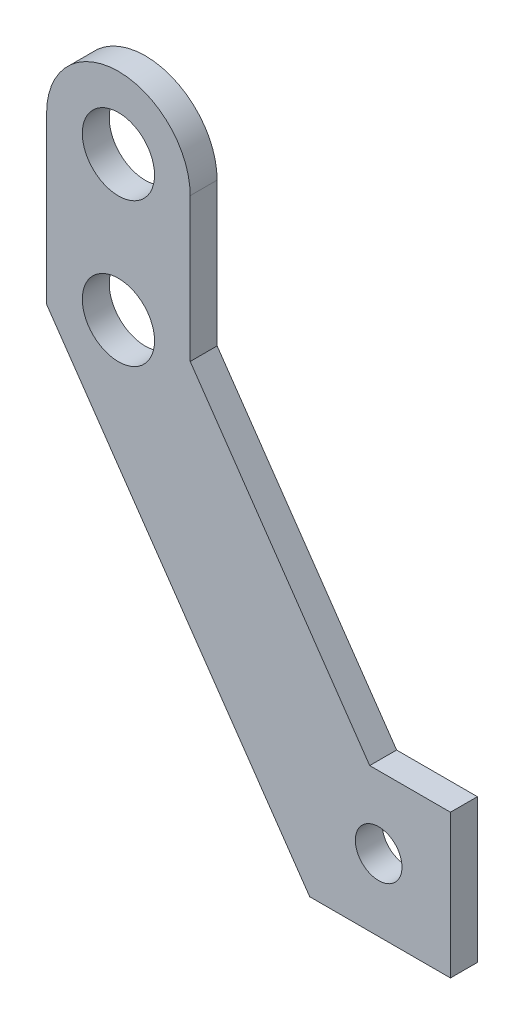
from build123d import *

# Parameters (mm, degrees)
SKETCH_1_R      = 2.6
SKETCH_1_R_2    = 4.025
EXTRUDE_1_DEPTH = 3


with BuildPart() as part:
    # ｽｹｯﾁ1 → ﾎﾞｽ - 押し出し1 (new body)
    with BuildSketch(Plane.XY):
        with BuildLine():
            Line((0, 46), (0, 27.508868037))
            Line((0, 27.508868037), (29.316460715, -15))
            Line((29.316460715, -15), (45, -15))
            Line((45, -15), (45, 1))
            Line((45, 1), (36, 1))
            Line((36, 1), (16, 30))
            Line((16, 30), (16, 46))
            ThreePointArc((16, 46), (8, 54), (0, 46))
        make_face()
        with Locations((37, -7)):
            Circle(SKETCH_1_R, mode=Mode.SUBTRACT)
        with Locations((8, 46)):
            Circle(SKETCH_1_R_2, mode=Mode.SUBTRACT)
        with Locations((8, 30)):
            Circle(SKETCH_1_R_2, mode=Mode.SUBTRACT)
    extrude(amount=EXTRUDE_1_DEPTH)


solid = part.part
